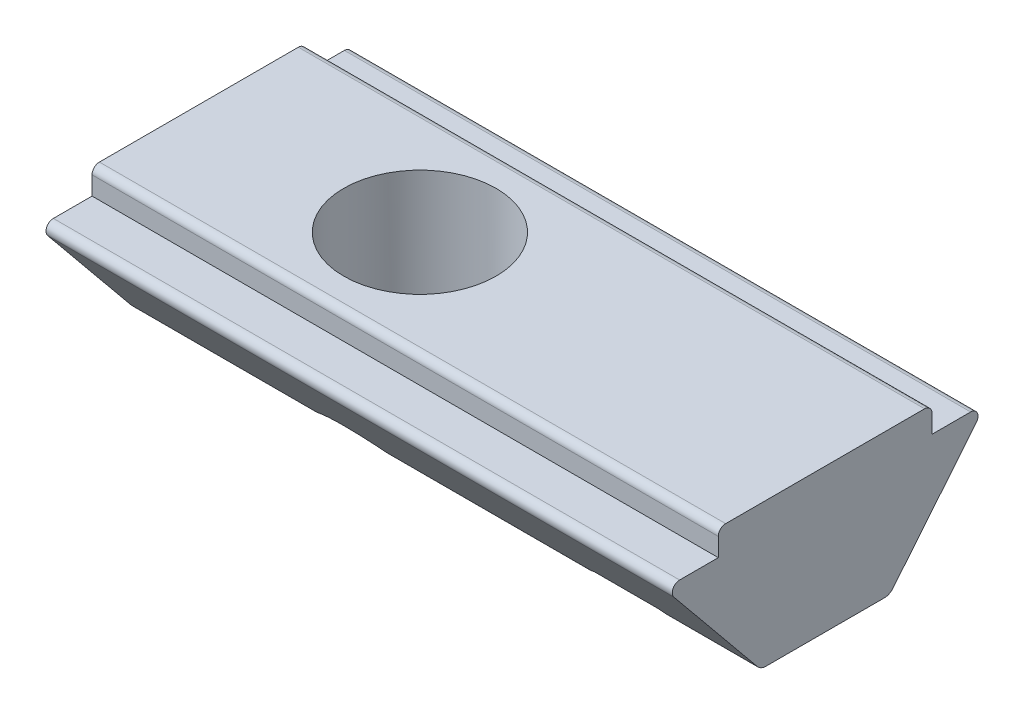
from build123d import *

# Parameters (mm, degrees)
BOSS_EXTRUDE1_DEPTH = 17
FILLET1_R           = 0.3
FILLET2_R           = 0.2
SKETCH2_W           = 2.1
SKETCH2_H           = 0.2
TAPPED_HOLE1_D      = 4.134


with BuildPart() as part:
    # Sketch1 → Boss-Extrude1 (new body)
    with BuildSketch(Plane(origin=(-6, 0, 0), x_dir=(0, 0, -1), z_dir=(1, 0, 0))):
        with BuildLine():
            Line((2.9, 0), (-2.9, 0))
            Line((-2.9, 0), (-2.9, -0.7))
            Line((-2.9, -0.7), (-3.95, -0.7))
            ThreePointArc((-3.95, -0.7), (-4.13076842, -0.814426765), (-4.104689384, -1.026772215))
            Line((-4.104689384, -1.026772215), (-1.75, -3.9))
            Line((-1.75, -3.9), (1.75, -3.9))
            Line((1.75, -3.9), (4.104689384, -1.026772215))
            ThreePointArc((4.104689384, -1.026772215), (4.13076842, -0.814426765), (3.95, -0.7))
            Line((3.95, -0.7), (2.9, -0.7))
            Line((2.9, -0.7), (2.9, 0))
        make_face()
    extrude(amount=BOSS_EXTRUDE1_DEPTH)

    # Fillet1
    fillet1_edges = [part.edges().sort_by_distance(p)[0] for p in [
        (2.5, -3.9, -1.75),
        (2.5, -3.9, 1.75),
    ]]
    fillet(fillet1_edges, radius=FILLET1_R)

    # Fillet2
    fillet2_edges = [part.edges().sort_by_distance(p)[0] for p in [
        (2.5, 0, 2.9),
        (2.5, 0, -2.9),
    ]]
    fillet(fillet2_edges, radius=FILLET2_R)

    # Sketch2 → Cut-Revolve1 (revolve, cut)
    with BuildSketch(Plane(origin=(7.5, 0, 0), x_dir=(0, 0, -1), z_dir=(1, 0, 0))):
        with Locations((1.05, -3.8)):
            Rectangle(SKETCH2_W, SKETCH2_H)
    revolve(axis=Axis((7.5, 1.665548573, 0), (0, -1, 0)), mode=Mode.SUBTRACT)

    # Sketch3 → Revolve1 (revolve)
    with BuildSketch(Plane(origin=(7.5, 0, 0), x_dir=(0, 0, -1), z_dir=(1, 0, 0))):
        with BuildLine():
            Line((1.732050808, -3.7), (0, -3.7))
            Line((0, -3.7), (0, -4.7))
            ThreePointArc((0, -4.7), (1, -4.432050808), (1.732050808, -3.7))
        make_face()
    revolve(axis=Axis((7.5, 0, 0), (0, -1, 0)))

    # Tapped Hole1 (through all)
    with Locations(Plane(origin=(0, 0, 0), x_dir=(1, 0, 0), z_dir=(0, 1, 0))):
        with Locations((0, 0)):
            Hole(TAPPED_HOLE1_D / 2)


solid = part.part
